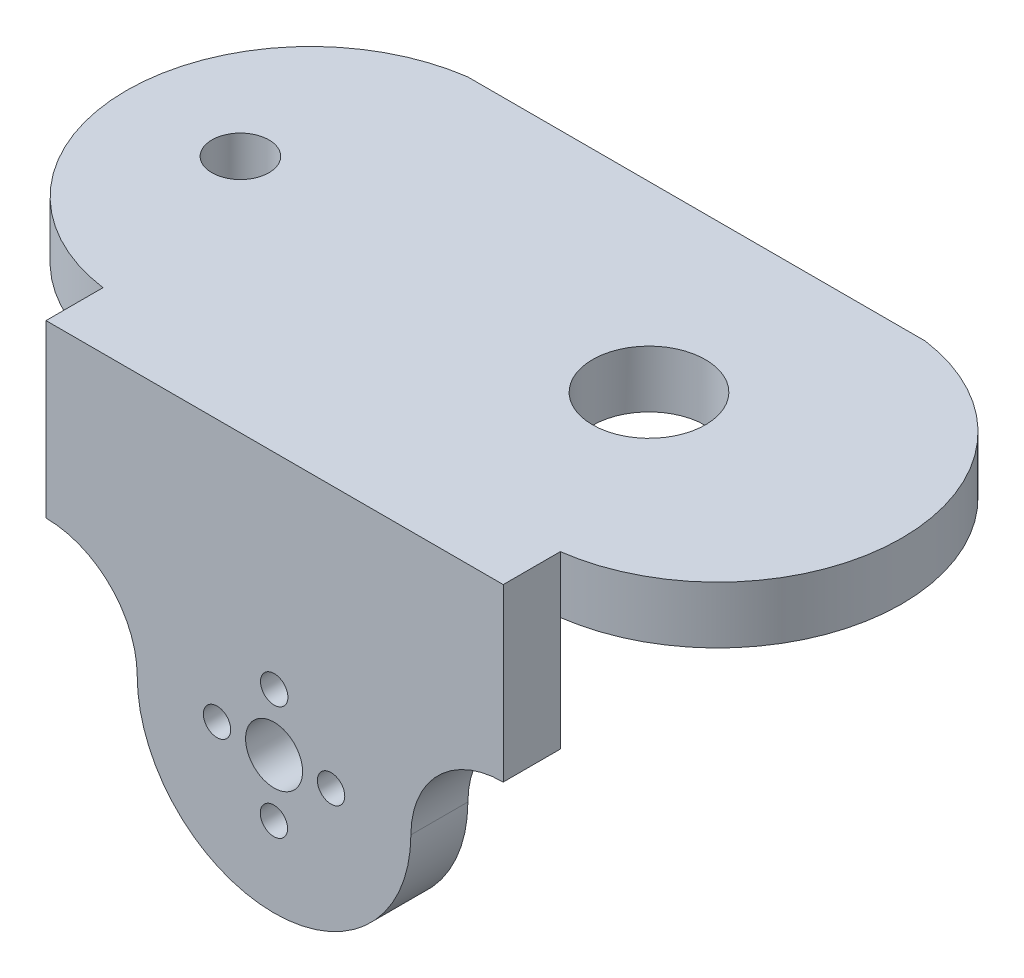
from build123d import *

# Parameters (mm, degrees)
SKETCH1_W           = 40.1
SKETCH1_H           = 10
BOSS_EXTRUDE1_DEPTH = 5
SKETCH2_W           = 40.1
SKETCH2_H           = 5
BOSS_EXTRUDE2_DEPTH = 37
BOSS_EXTRUDE3_DEPTH = 5
SKETCH4_R           = 1.2
SKETCH4_R_2         = 2.5
CUT_EXTRUDE1_DEPTH  = 38
SKETCH5_R           = 4.955
SKETCH5_R_2         = 2.5
CUT_EXTRUDE2_DEPTH  = 36


with BuildPart() as part:
    # Sketch1 → Boss-Extrude1 (new body)
    with BuildSketch(Plane.XY):
        with Locations((20.05, -5)):
            Rectangle(SKETCH1_W, SKETCH1_H)
        with BuildLine():
            ThreePointArc((8, -18), (19.970074906, -29.999962687), (31.999850748, -18.059850002))
            ThreePointArc((31.999850748, -18.059850002), (34.386559706, -12.358242505), (40.1, -10))
            Line((40.1, -10), (0, -10))
            ThreePointArc((0, -10), (5.656854249, -12.343145751), (8, -18))
        make_face()
    extrude(amount=BOSS_EXTRUDE1_DEPTH)

    # Sketch2 → Boss-Extrude2 (add)
    with BuildSketch(Plane.XY.offset(5)):
        with Locations((20.05, 2.5)):
            Rectangle(SKETCH2_W, SKETCH2_H)
    extrude(amount=-BOSS_EXTRUDE2_DEPTH)

    # Sketch3 → Boss-Extrude3 (add)
    with BuildSketch(Plane(origin=(0, 5, 0), x_dir=(1, 0, 0), z_dir=(0, 1, 0))):
        with BuildLine():
            Line((0, 32), (0, 0))
            ThreePointArc((0, 0), (-13.95, 16), (0, 32))
        make_face()
        with BuildLine():
            Line((40.1, 32), (40.1, 0))
            ThreePointArc((40.1, 0), (54.05, 16), (40.1, 32))
        make_face()
    extrude(amount=-BOSS_EXTRUDE3_DEPTH)

    # Sketch4 → Cut-Extrude1 (cut, through all)
    with BuildSketch(Plane.XY.offset(5)):
        with Locations((20.012468828, -13)):
            Circle(SKETCH4_R)
        with Locations((20, -18)):
            Circle(SKETCH4_R_2)
        with Locations((15, -17.975062189)):
            Circle(SKETCH4_R)
        with Locations((19.987531172, -23)):
            Circle(SKETCH4_R)
        with Locations((25, -18.024937811)):
            Circle(SKETCH4_R)
    extrude(amount=-CUT_EXTRUDE1_DEPTH, mode=Mode.SUBTRACT)

    # Sketch5 → Cut-Extrude2 (cut, through all)
    with BuildSketch(Plane(origin=(0, 5, 0), x_dir=(1, 0, 0), z_dir=(0, 1, 0))):
        with Locations((31.88, 16)):
            Circle(SKETCH5_R)
        with Locations((-3.95, 16)):
            Circle(SKETCH5_R_2)
    extrude(amount=-CUT_EXTRUDE2_DEPTH, mode=Mode.SUBTRACT)


solid = part.part
